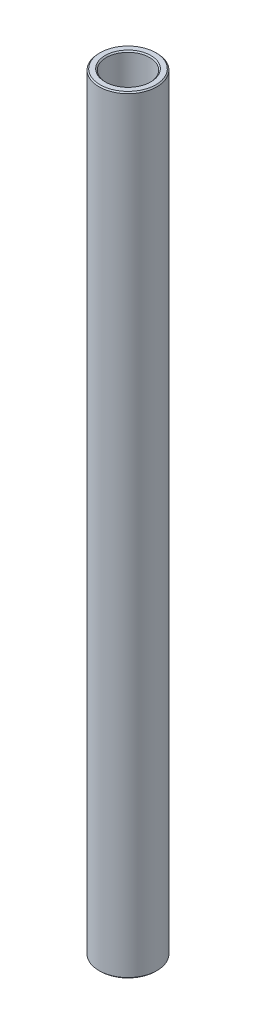
from build123d import *

# Parameters (mm, degrees)
SKETCH1_W     = 1.5875
SKETCH1_H     = 168.275
CHAMFER1_SIZE = 0.254


with BuildPart() as part:
    # Sketch1 → Revolve1 (revolve)
    with BuildSketch(Plane.XY):
        with Locations((5.55625, 0)):
            Rectangle(SKETCH1_W, SKETCH1_H)
    revolve(axis=Axis((0, 11.60859375, 0), (0, -1, 0)))

    # Chamfer1
    chamfer1_edges = [part.edges().sort_by_distance(p)[0] for p in [
        (-4.7625, -84.1375, 0),
        (-6.35, -84.1375, 0),
        (-6.35, 84.1375, 0),
        (-4.7625, 84.1375, 0),
    ]]
    chamfer(chamfer1_edges, length=CHAMFER1_SIZE)


solid = part.part
